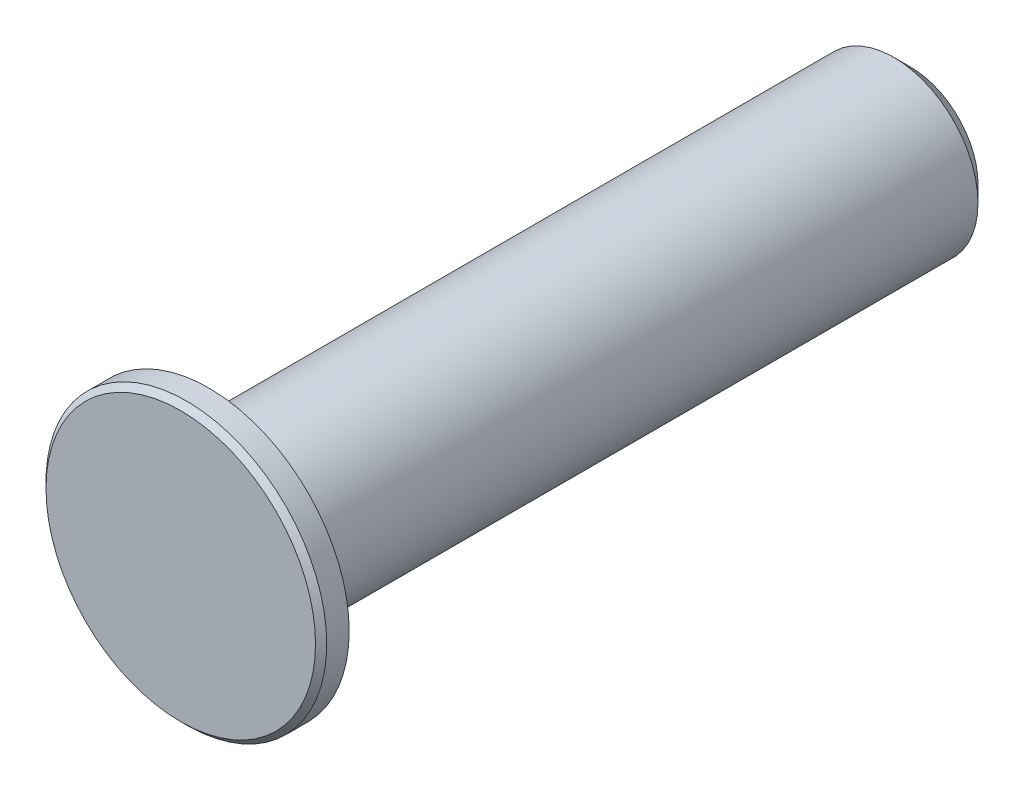
from build123d import *

# Parameters (mm, degrees)
SKETCH1_R           = 3
BOSS_EXTRUDE1_DEPTH = 25
SKETCH2_R           = 5
BOSS_EXTRUDE2_DEPTH = 1
CHAMFER1_SIZE       = 0.6
CHAMFER2_SIZE       = 0.2


with BuildPart() as part:
    # Sketch1 → Boss-Extrude1 (new body)
    with BuildSketch(Plane.XY):
        Circle(SKETCH1_R)
    extrude(amount=BOSS_EXTRUDE1_DEPTH)

    # Sketch2 → Boss-Extrude2 (add)
    with BuildSketch(Plane.XY.offset(25)):
        Circle(SKETCH2_R)
    extrude(amount=BOSS_EXTRUDE2_DEPTH)

    # Chamfer1
    chamfer1_edges = [part.edges().sort_by_distance(p)[0] for p in [
        (-3, 0, 0),
    ]]
    chamfer(chamfer1_edges, length=CHAMFER1_SIZE)

    # Chamfer2
    chamfer2_edges = [part.edges().sort_by_distance(p)[0] for p in [
        (-5, 0, 26),
    ]]
    chamfer(chamfer2_edges, length=CHAMFER2_SIZE)


solid = part.part
